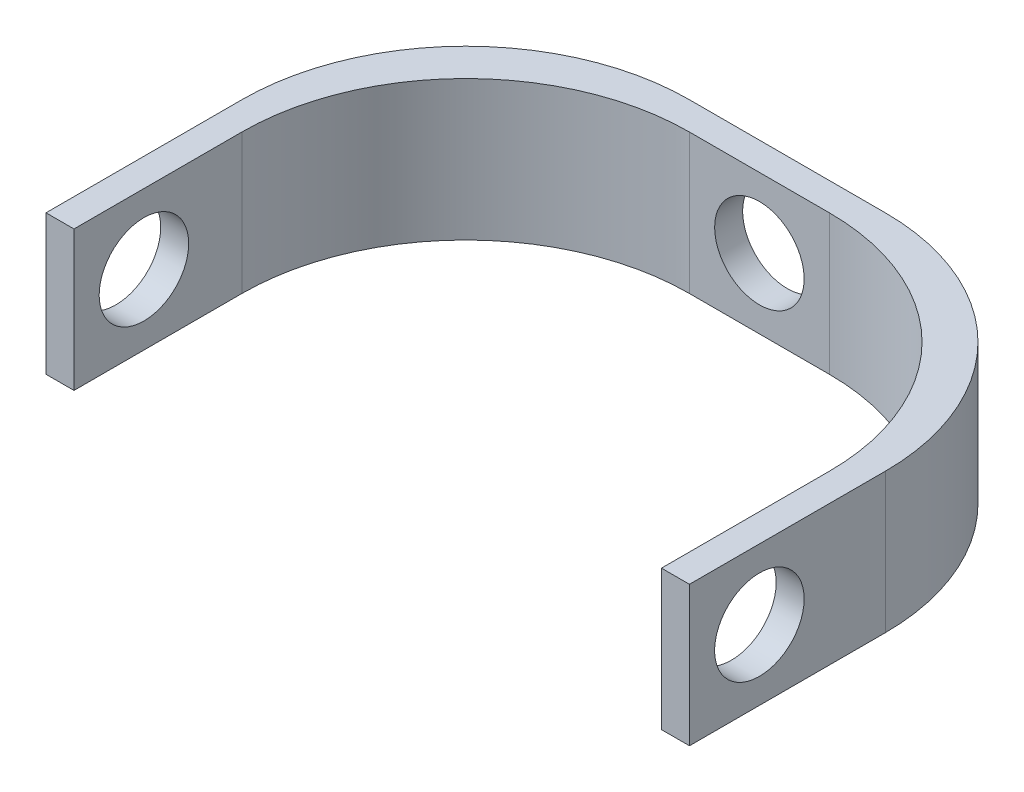
from build123d import *

# Parameters (mm, degrees)
BOSS_EXTRUDE1_DEPTH = 5
SKETCH2_R           = 1.6
CUT_EXTRUDE1_DEPTH  = 5
SKETCH3_R           = 1.6
CUT_EXTRUDE2_DEPTH  = 27
FILLET1_R           = 8


with BuildPart() as part:
    # Sketch1 → Boss-Extrude1 (new body)
    with BuildSketch(Plane(origin=(0, 0, 0), x_dir=(1, 0, 0), z_dir=(0, 1, 0))):
        Polygon((0, 0), (1, 0), (1, 14), (22, 14), (22, 0), (23, 0), (23, 15), (0, 15), align=None)
    extrude(amount=BOSS_EXTRUDE1_DEPTH)

    # Sketch2 → Cut-Extrude1 (cut)
    with BuildSketch(Plane(origin=(0, 0, -15), x_dir=(-1, 0, 0), z_dir=(0, 0, -1))):
        with Locations((-11.5, 2.5)):
            Circle(SKETCH2_R)
    extrude(amount=-CUT_EXTRUDE1_DEPTH, mode=Mode.SUBTRACT)

    # Sketch3 → Cut-Extrude2 (cut)
    with BuildSketch(Plane(origin=(23, 0, 0), x_dir=(0, 0, -1), z_dir=(1, 0, 0))):
        with Locations((2.5, 2.5)):
            Circle(SKETCH3_R)
    extrude(amount=-CUT_EXTRUDE2_DEPTH, mode=Mode.SUBTRACT)

    # Fillet1
    fillet1_edges = [part.edges().sort_by_distance(p)[0] for p in [
        (0, 2.5, -15),
        (23, 2.5, -15),
        (22, 2.5, -14),
        (1, 2.5, -14),
    ]]
    fillet(fillet1_edges, radius=FILLET1_R)


solid = part.part
